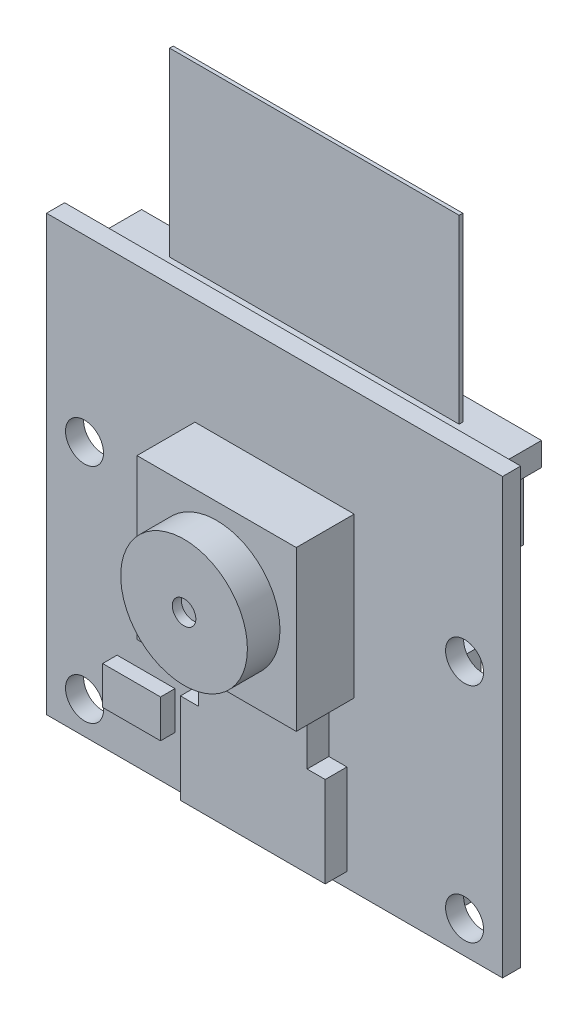
from build123d import *

# Parameters (mm, degrees)
SKICA1_W                 = 25.2
SKICA1_H                 = 24
SKICA1_R                 = 1.05
SKICA1_W_2               = 8.8
SKICA1_H_2               = 8.8
SKICA1_R_2               = 3.5
P_IDAT_VYSUNUT_M1_DEPTH  = 1
SKICA1_3_W               = 8.8
SKICA1_3_H               = 8.8
SKICA1_3_R               = 3.5
P_IDAT_VYSUNUT_M2_DEPTH  = 3.2
SKICA1_4_R               = 3.5
P_IDAT_VYSUNUT_M3_DEPTH  = 5
SKICA2_W                 = 8
SKICA2_H                 = 5
SKICA2_W_2               = 6
SKICA2_H_2               = 3.5
P_IDAT_VYSUNUT_M4_DEPTH  = 1.2
SKICA3_W                 = 20.1
SKICA3_H                 = 4.2
P_IDAT_VYSUNUT_M5_DEPTH  = 2.7
SKICA4_W                 = 17.9
SKICA4_H                 = 12
P_IDAT_VYSUNUT_M6_DEPTH  = 1.3
SKICA5_W                 = 3.2
SKICA5_H                 = 2.1
P_IDAT_VYSUNUT_M7_DEPTH  = 0.8
SKICA6_R                 = 0.65
ODEBRAT_VYSUNUT_M1_DEPTH = 0.5
SKICA7_W                 = 16
SKICA7_H                 = 0.2
P_IDAT_VYSUNUT_M9_DEPTH  = 10


with BuildPart() as part:
    # Skica1 → P_idat vysunut_m1 (new body)
    with BuildSketch(Plane.XY):
        Rectangle(SKICA1_W, SKICA1_H)
        with Locations((10.5, 2.1)):
            Circle(SKICA1_R, mode=Mode.SUBTRACT)
        with Locations((-10.5, 2.1)):
            Circle(SKICA1_R, mode=Mode.SUBTRACT)
        with Locations((10.5, -10.2)):
            Circle(SKICA1_R, mode=Mode.SUBTRACT)
        with Locations((-10.5, -10.2)):
            Circle(SKICA1_R, mode=Mode.SUBTRACT)
        with Locations((0, 1.7)):
            Rectangle(SKICA1_W_2, SKICA1_H_2, mode=Mode.SUBTRACT)
        with Locations((0, 1.7)):
            Rectangle(SKICA1_W_2, SKICA1_H_2)
        with Locations((0, 1.7)):
            Circle(SKICA1_R_2, mode=Mode.SUBTRACT)
        with Locations((0, 1.7)):
            Circle(SKICA1_R_2)
    extrude(amount=-P_IDAT_VYSUNUT_M1_DEPTH)

    # Skica1_3 → P_idat vysunut_m2 (add)
    with BuildSketch(Plane.XY):
        with Locations((0, 1.7)):
            Rectangle(SKICA1_3_W, SKICA1_3_H)
        with Locations((0, 1.7)):
            Circle(SKICA1_3_R, mode=Mode.SUBTRACT)
    extrude(amount=P_IDAT_VYSUNUT_M2_DEPTH)

    # Skica1_4 → P_idat vysunut_m3 (add)
    with BuildSketch(Plane.XY):
        with Locations((0, 1.7)):
            Circle(SKICA1_4_R)
    extrude(amount=P_IDAT_VYSUNUT_M3_DEPTH)

    # Skica2 → P_idat vysunut_m4 (add)
    with BuildSketch(Plane.XY):
        with Locations((0, -8.7)):
            Rectangle(SKICA2_W, SKICA2_H)
        with Locations((0, -4.45)):
            Rectangle(SKICA2_W_2, SKICA2_H_2)
    extrude(amount=P_IDAT_VYSUNUT_M4_DEPTH)

    # Skica3 → P_idat vysunut_m5 (add)
    with BuildSketch(Plane(origin=(0, 0, -1), x_dir=(-1, 0, 0), z_dir=(0, 0, -1))):
        with Locations((0, 7.7)):
            Rectangle(SKICA3_W, SKICA3_H)
        Polygon((-11.05, 9.8), (-10.05, 9.8), (10.05, 9.8), (11.05, 9.8), (11.05, 11.1), (-11.05, 11.1), align=None)
    extrude(amount=P_IDAT_VYSUNUT_M5_DEPTH)

    # Skica4 → P_idat vysunut_m6 (add)
    with BuildSketch(Plane(origin=(0, 0, -1), x_dir=(-1, 0, 0), z_dir=(0, 0, -1))):
        with Locations((-0.15, -5)):
            Rectangle(SKICA4_W, SKICA4_H)
    extrude(amount=P_IDAT_VYSUNUT_M6_DEPTH)

    # Skica5 → P_idat vysunut_m7 (add)
    with BuildSketch(Plane.XY):
        with Locations((-7.1, -8.25)):
            Rectangle(SKICA5_W, SKICA5_H)
    extrude(amount=P_IDAT_VYSUNUT_M7_DEPTH)

    # Skica6 → Odebrat vysunut_m1 (cut)
    with BuildSketch(Plane.XY.offset(5)):
        with Locations((0, 1.7)):
            Circle(SKICA6_R)
    extrude(amount=-ODEBRAT_VYSUNUT_M1_DEPTH, mode=Mode.SUBTRACT)

    # Skica7 → P_idat vysunut_m9 (add)
    with BuildSketch(Plane(origin=(0, 11.1, 0), x_dir=(1, 0, 0), z_dir=(0, 1, 0))):
        with Locations((0, 2.3)):
            Rectangle(SKICA7_W, SKICA7_H)
    extrude(amount=P_IDAT_VYSUNUT_M9_DEPTH)


solid = part.part
